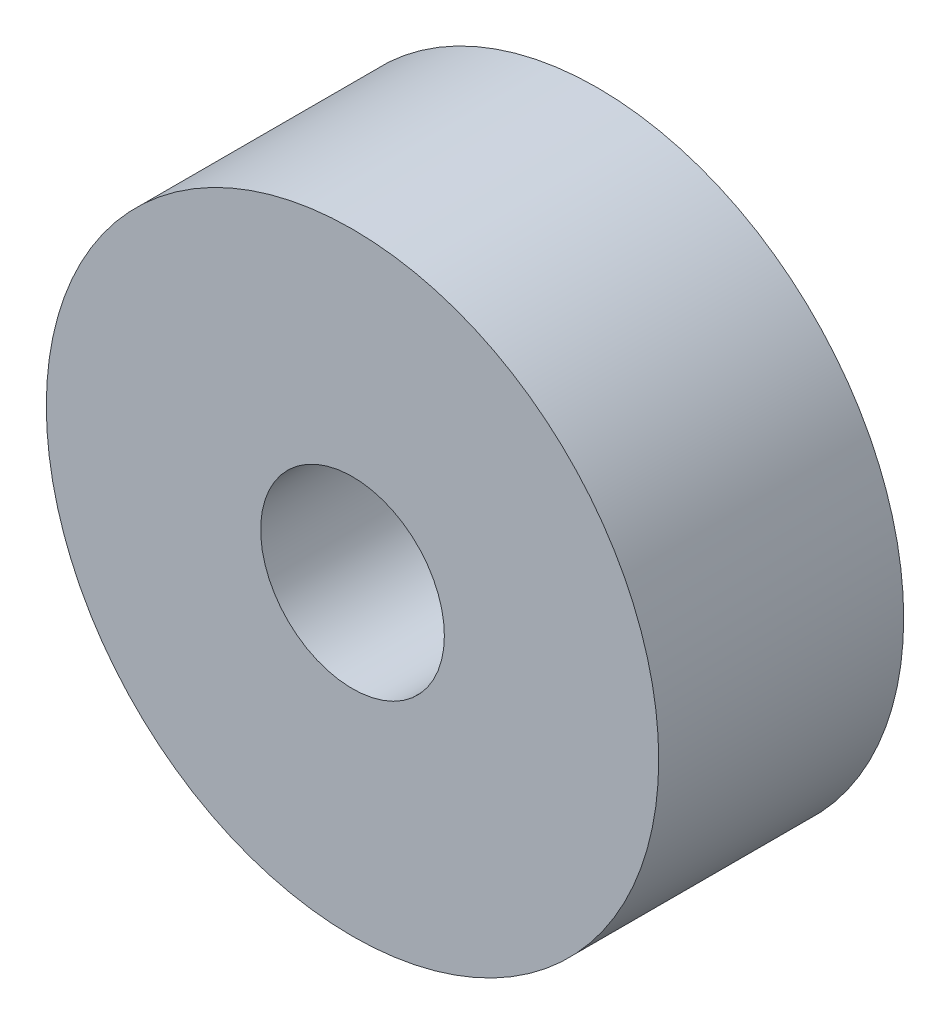
from build123d import *

# Parameters (mm, degrees)
ESBO_O1_R                = 5
ESBO_O1_R_2              = 1.5
RESSALTO_EXTRUS_O1_DEPTH = 4


with BuildPart() as part:
    # Esboço1 → Ressalto-extrusão1 (new body)
    with BuildSketch(Plane.XY):
        Circle(ESBO_O1_R)
        Circle(ESBO_O1_R_2, mode=Mode.SUBTRACT)
    extrude(amount=RESSALTO_EXTRUS_O1_DEPTH)


solid = part.part
